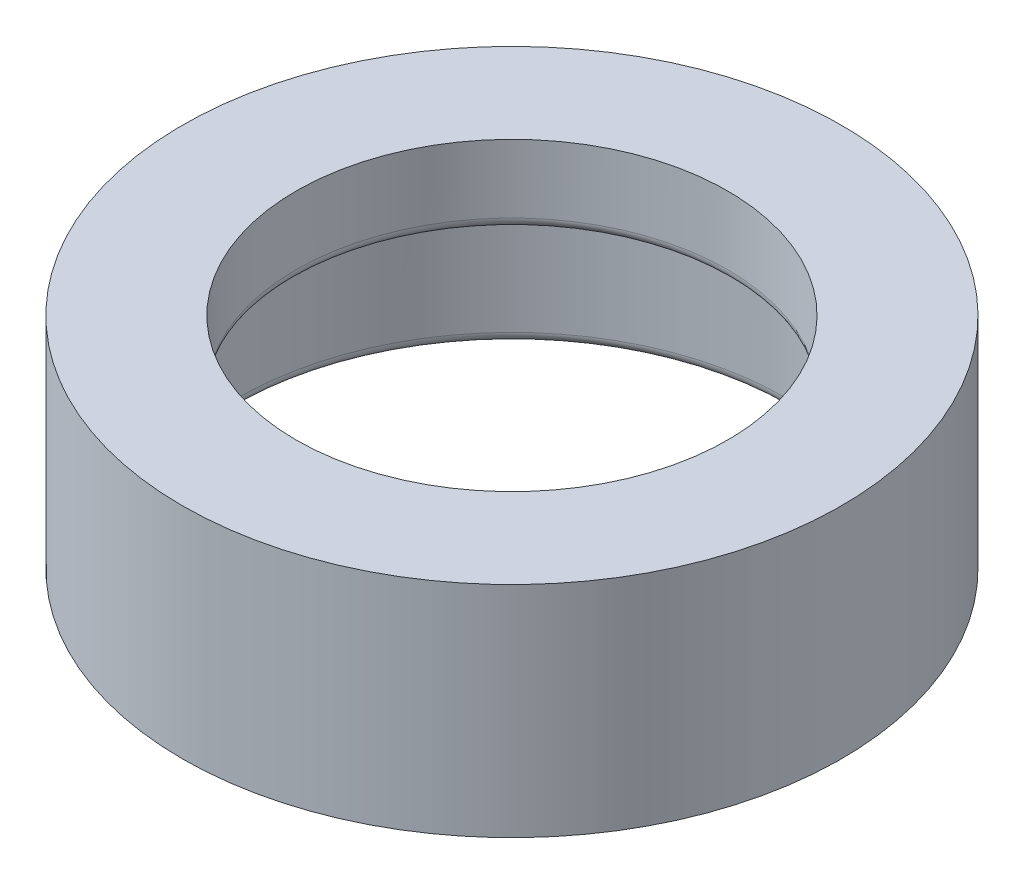
from build123d import *

# Parameters (mm, degrees)
SKETCH1_R           = 30.55
BOSS_EXTRUDE1_DEPTH = 20.32
SKETCH2_R           = 25.404
CUT_EXTRUDE1_DEPTH  = 13
SKETCH3_R           = 20
CUT_EXTRUDE2_DEPTH  = 21.32
FILLET1_R           = 1
FILLET2_R           = 1


with BuildPart() as part:
    # Sketch1 → Boss-Extrude1 (new body)
    with BuildSketch(Plane(origin=(0, 0, 0), x_dir=(1, 0, 0), z_dir=(0, 1, 0))):
        Circle(SKETCH1_R)
    extrude(amount=BOSS_EXTRUDE1_DEPTH)

    # Sketch2 → Cut-Extrude1 (cut)
    with BuildSketch(Plane.XZ):
        Circle(SKETCH2_R)
    extrude(amount=-CUT_EXTRUDE1_DEPTH, mode=Mode.SUBTRACT)

    # Sketch3 → Cut-Extrude2 (cut, through all)
    with BuildSketch(Plane(origin=(0, 20.32, 0), x_dir=(1, 0, 0), z_dir=(0, 1, 0))):
        Circle(SKETCH3_R)
    extrude(amount=-CUT_EXTRUDE2_DEPTH, mode=Mode.SUBTRACT)

    # Fillet1
    fillet1_edges = [part.edges().sort_by_distance(p)[0] for p in [
        (-25.404, 0, 0),
    ]]
    fillet(fillet1_edges, radius=FILLET1_R)

    # Fillet2
    fillet2_edges = [part.edges().sort_by_distance(p)[0] for p in [
        (-20, 13, 0),
    ]]
    fillet(fillet2_edges, radius=FILLET2_R)


solid = part.part
